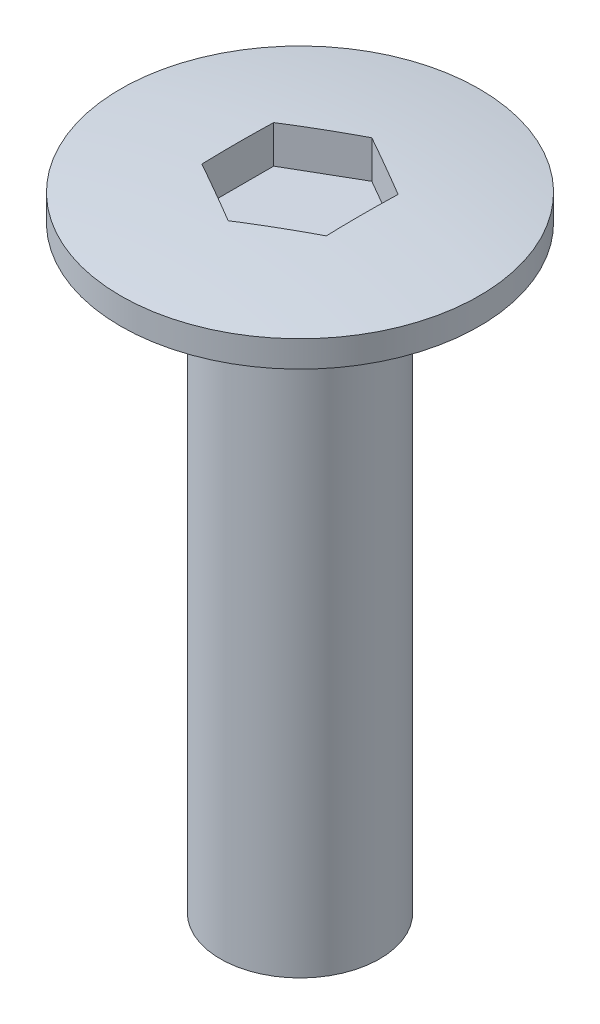
from build123d import *

# Parameters (mm, degrees)
SKETCH_1_R          = 4.5
EXTRUDE_1_DEPTH     = 1
SKETCH_2_R          = 2
EXTRUDE_2_DEPTH     = 15
CUT_EXTRUDE_1_DEPTH = 1


with BuildPart() as part:
    # 草图1 → 凸台-拉伸1 (new body)
    with BuildSketch(Plane(origin=(0, 0, 0), x_dir=(1, 0, 0), z_dir=(0, 1, 0))):
        Circle(SKETCH_1_R)
    extrude(amount=EXTRUDE_1_DEPTH)

    # 草图2 → 凸台-拉伸2 (add)
    with BuildSketch(Plane.XZ):
        Circle(SKETCH_2_R)
    extrude(amount=EXTRUDE_2_DEPTH)

    # 草图3 → 切除-旋转2 (revolve, cut)
    with BuildSketch(Plane.XY):
        with BuildLine():
            ThreePointArc((5.590055425, 0.474587026), (2.807346543, 0.868357929), (0, 1))
            Line((0, 1), (0, 3.329372604))
            Line((0, 3.329372604), (5.734393967, 3.279293278))
            Line((5.734393967, 3.279293278), (5.590055425, 0.474587026))
        make_face()
    revolve(axis=Axis((0, 0, 0), (0, 1, 0)), mode=Mode.SUBTRACT)

    # 草图4 → 切除-拉伸1 (cut)
    with BuildSketch(Plane.XZ):
        Polygon((0, -1.802383699), (1.56091007, -0.901191849), (1.56091007, 0.901191849), (0, 1.802383699), (-1.56091007, 0.901191849), (-1.56091007, -0.901191849), align=None)
    extrude(amount=-CUT_EXTRUDE_1_DEPTH, mode=Mode.SUBTRACT)


solid = part.part
